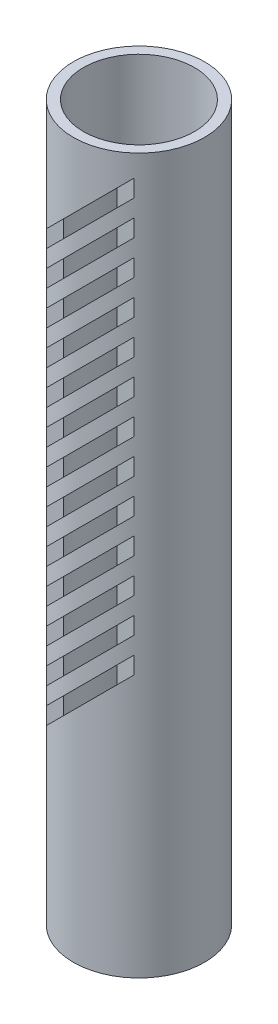
from build123d import *

# Parameters (mm, degrees)
SKETCH1_R           = 25.654
SKETCH1_R_2         = 21.717
BOSS_EXTRUDE1_DEPTH = 279.4
CUT_EXTRUDE1_START  = 19.05
CUT_EXTRUDE1_DEPTH  = 12.7
LPATTERN1_COUNT     = 13
LPATTERN1_PITCH     = 13.462


with BuildPart() as part:
    # Sketch1 → Boss-Extrude1 (new body)
    with BuildSketch(Plane(origin=(0, 0, 0), x_dir=(1, 0, 0), z_dir=(0, 1, 0))):
        with Locations(Location((0, 0, 0), (0, 0, 270))):  # turned: the seam where the file's is
            Circle(SKETCH1_R)
        with Locations(Location((0, 0, 0), (0, 0, 270))):  # turned: the seam where the file's is
            Circle(SKETCH1_R_2, mode=Mode.SUBTRACT)
    extrude(amount=BOSS_EXTRUDE1_DEPTH)

    # Sketch2 → Cut-Extrude1 (cut)
    with BuildSketch(Plane.XY.offset(CUT_EXTRUDE1_START)):
        Polygon((-29.021596045, 224.724403955), (-25.654, 221.356807909), (29.021596045, 276.032403955), (25.654, 279.4), align=None)
    cut_extrude1 = extrude(amount=CUT_EXTRUDE1_DEPTH, mode=Mode.SUBTRACT)

    # LPattern1: Cut-Extrude1 ×13
    with Locations(*[(0, -i * LPATTERN1_PITCH, 0) for i in range(1, LPATTERN1_COUNT)]):
        add(cut_extrude1, mode=Mode.SUBTRACT)


solid = part.part
